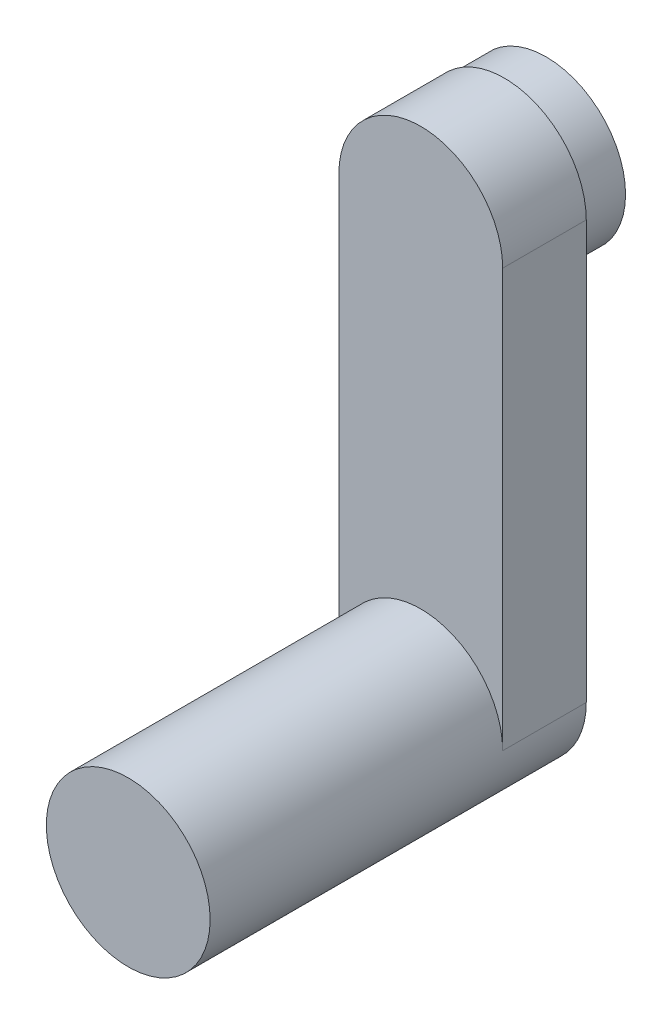
from build123d import *

# Parameters (mm, degrees)
SKETCH1_R           = 49
BOSS_EXTRUDE1_DEPTH = 175
BOSS_EXTRUDE2_START = 50
BOSS_EXTRUDE2_DEPTH = 50
SKETCH3_R           = 47.5
SKETCH3_R_2         = 45
BOSS_EXTRUDE3_DEPTH = 25


with BuildPart() as part:
    # Sketch1 → Boss-Extrude1 (new body)
    with BuildSketch(Plane.XY):
        Circle(SKETCH1_R)
    extrude(amount=BOSS_EXTRUDE1_DEPTH)

    # Sketch2 → Boss-Extrude2 (add)
    with BuildSketch(Plane(origin=(0, 0, 0), x_dir=(-1, 0, 0), z_dir=(0, 0, -1)).offset(BOSS_EXTRUDE2_START)):
        with BuildLine():
            Line((-49, 0), (-49, 250))
            ThreePointArc((-49, 250), (0, 299), (49, 250))
            Line((49, 250), (49, 0))
            ThreePointArc((49, 0), (0, -49), (-49, 0))
        make_face()
    extrude(amount=-BOSS_EXTRUDE2_DEPTH)

    # Sketch3 → Boss-Extrude3 (add)
    with BuildSketch(Plane(origin=(0, 0, -50), x_dir=(-1, 0, 0), z_dir=(0, 0, -1))):
        with Locations((0, 250)):
            Circle(SKETCH3_R)
        with Locations((0, 250)):
            Circle(SKETCH3_R_2, mode=Mode.SUBTRACT)
    extrude(amount=BOSS_EXTRUDE3_DEPTH)


solid = part.part
